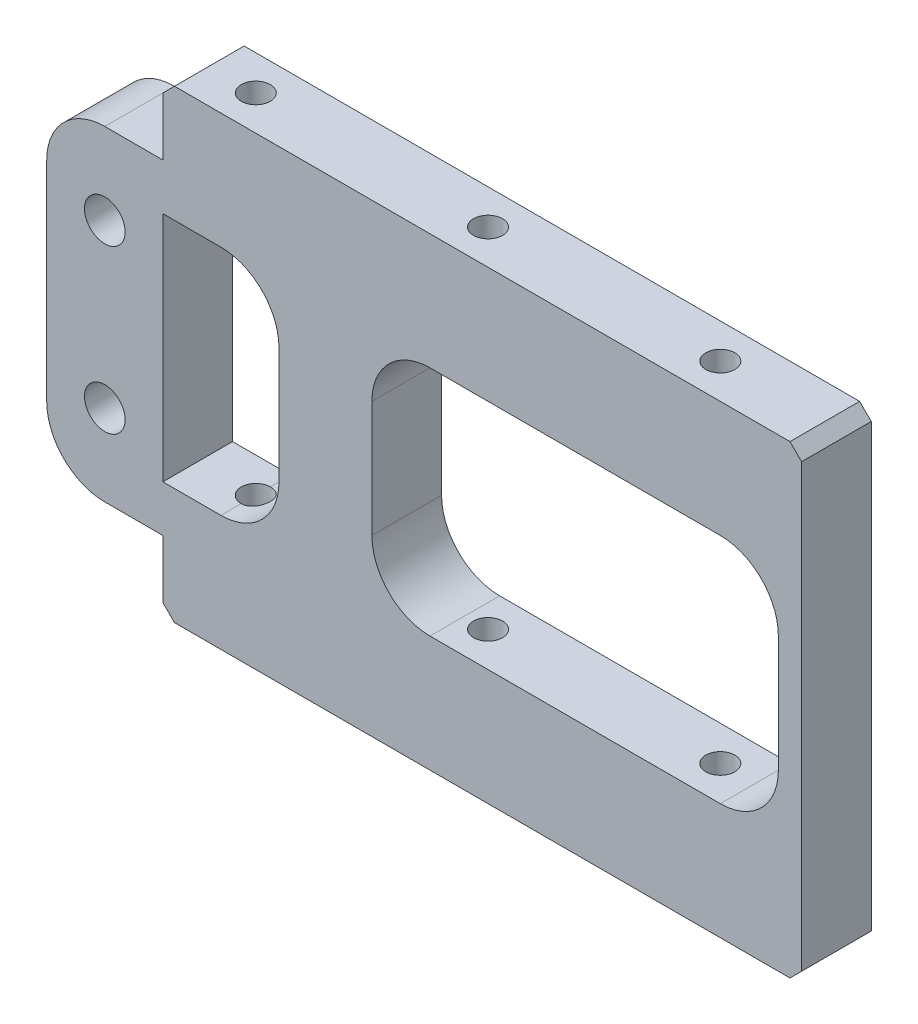
from build123d import *

# Parameters (mm, degrees)
SKETCH1_W           = 55
SKETCH1_H           = 6
BOSS_EXTRUDE1_DEPTH = 40
M3_TAPPED_HOLE1_D   = 2.5
CUT_EXTRUDE1_DEPTH  = 40
CHAMFER1_SIZE       = 1
SKETCH9_R           = 1.75
BOSS_EXTRUDE4_DEPTH = 6


with BuildPart() as part:
    # Sketch1 → Boss-Extrude1 (new body)
    with BuildSketch(Plane(origin=(0, 0, 0), x_dir=(1, 0, 0), z_dir=(0, 1, 0))):
        Rectangle(SKETCH1_W, SKETCH1_H)
    extrude(amount=BOSS_EXTRUDE1_DEPTH)

    # M3 Tapped Hole1 (through all)
    with Locations(Plane(origin=(-22.5, 40, 0), x_dir=(0, 0, 1), z_dir=(0, 1, 0))):
        with Locations((0, 0), (0, 20), (0, 40)):
            Hole(M3_TAPPED_HOLE1_D / 2)

    # Sketch7 → Cut-Extrude1 (cut)
    with BuildSketch(Plane(origin=(0, 0, -3), x_dir=(-1, 0, 0), z_dir=(0, 0, -1))):
        with BuildLine():
            Line((27.5, 30), (22.5, 30))
            ThreePointArc((22.5, 30), (18.964466094, 28.535533906), (17.5, 25))
            Line((17.5, 25), (17.5, 15))
            ThreePointArc((17.5, 15), (18.964466094, 11.464466094), (22.5, 10))
            Line((22.5, 10), (27.5, 10))
            Line((27.5, 10), (27.5, 30))
        make_face()
        with BuildLine():
            Line((4.5, 30), (-20.5, 30))
            ThreePointArc((-20.5, 30), (-24.035533906, 28.535533906), (-25.5, 25))
            Line((-25.5, 25), (-25.5, 15))
            ThreePointArc((-25.5, 15), (-24.035533906, 11.464466094), (-20.5, 10))
            Line((-20.5, 10), (4.5, 10))
            ThreePointArc((4.5, 10), (8.035533906, 11.464466094), (9.5, 15))
            Line((9.5, 15), (9.5, 25))
            ThreePointArc((9.5, 25), (8.035533906, 28.535533906), (4.5, 30))
        make_face()
    extrude(amount=-CUT_EXTRUDE1_DEPTH, mode=Mode.SUBTRACT)

    # Chamfer1
    chamfer1_edges = [part.edges().sort_by_distance(p)[0] for p in [
        (-27.5, 40, 0),
        (27.5, 40, 0),
        (-27.5, 0, 0),
        (27.5, 0, 0),
    ]]
    chamfer(chamfer1_edges, length=CHAMFER1_SIZE)

    # Sketch9 → Boss-Extrude4 (add)
    with BuildSketch(Plane(origin=(0, 0, -3), x_dir=(-1, 0, 0), z_dir=(0, 0, -1))):
        with BuildLine():
            Line((27.5, 34), (32.5, 34))
            ThreePointArc((32.5, 34), (36.035533906, 32.535533906), (37.5, 29))
            Line((37.5, 29), (37.5, 11))
            ThreePointArc((37.5, 11), (36.035533906, 7.464466094), (32.5, 6))
            Line((32.5, 6), (27.5, 6))
            Line((27.5, 6), (27.5, 34))
        make_face()
        with Locations((32.5, 27)):
            Circle(SKETCH9_R, mode=Mode.SUBTRACT)
        with Locations((32.5, 13)):
            Circle(SKETCH9_R, mode=Mode.SUBTRACT)
    extrude(amount=-BOSS_EXTRUDE4_DEPTH)


solid = part.part
